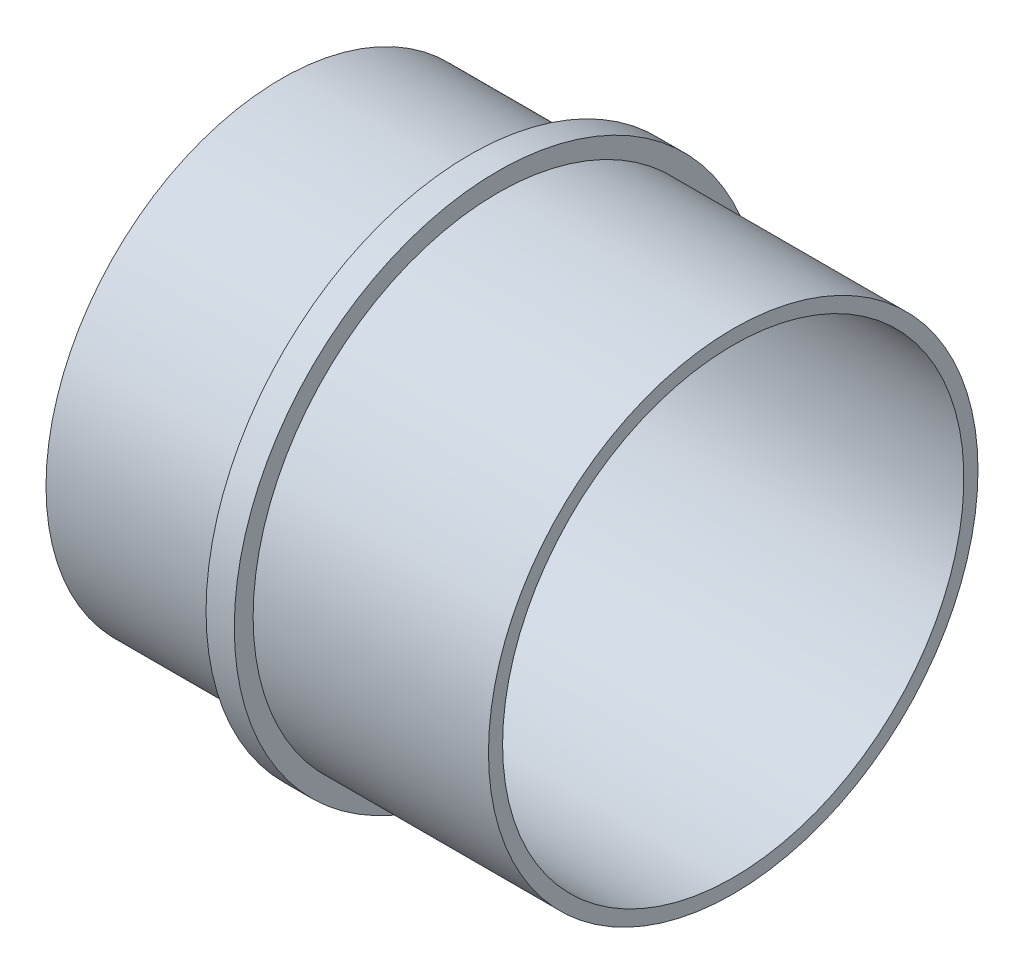
from build123d import *


with BuildPart() as part:
    # Esquisse1 → Révolution1 (revolve)
    with BuildSketch(Plane.XY, mode=Mode.PRIVATE) as r_volution1_sk:
        Polygon((0, 0), (24, 0), (24, 0.75), (11.5, 0.75), (11.5, 1.75), (10, 1.75), (10, 0.25), (0, 0.25), align=None)
    revolve(r_volution1_sk.sketch.rotate(Axis((-3, -12.25, 0), (1, 0, 0)), 90), axis=Axis((-3, -12.25, 0), (1, 0, 0)))  # turned: the seam where the file's is


solid = part.part
